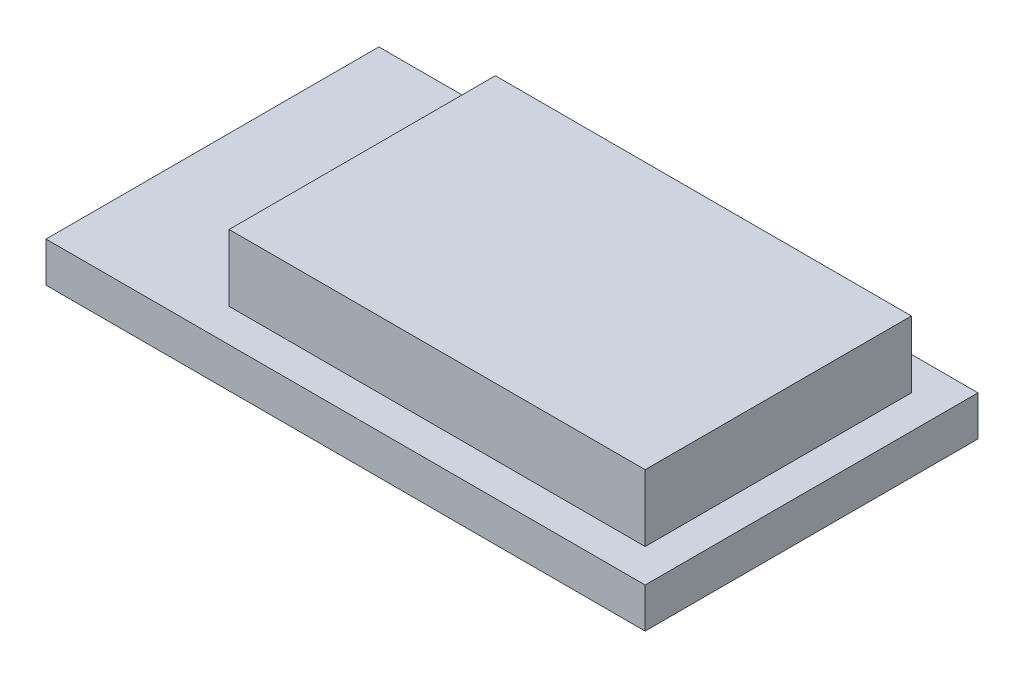
from build123d import *

# Parameters (mm, degrees)
SKETCH1_W           = 18
SKETCH1_H           = 10
BOSS_EXTRUDE1_DEPTH = 1.2
SKETCH2_W           = 12.5
SKETCH2_H           = 8
BOSS_EXTRUDE2_DEPTH = 2


with BuildPart() as part:
    # Sketch1 → Boss-Extrude1 (new body)
    with BuildSketch(Plane(origin=(0, 0, 0), x_dir=(1, 0, 0), z_dir=(0, 1, 0))):
        Rectangle(SKETCH1_W, SKETCH1_H)
    extrude(amount=-BOSS_EXTRUDE1_DEPTH)

    # Sketch2 → Boss-Extrude2 (add)
    with BuildSketch(Plane(origin=(0, 0, 0), x_dir=(1, 0, 0), z_dir=(0, 1, 0))):
        with Locations((1.75, 0)):
            Rectangle(SKETCH2_W, SKETCH2_H)
    extrude(amount=BOSS_EXTRUDE2_DEPTH)


solid = part.part
